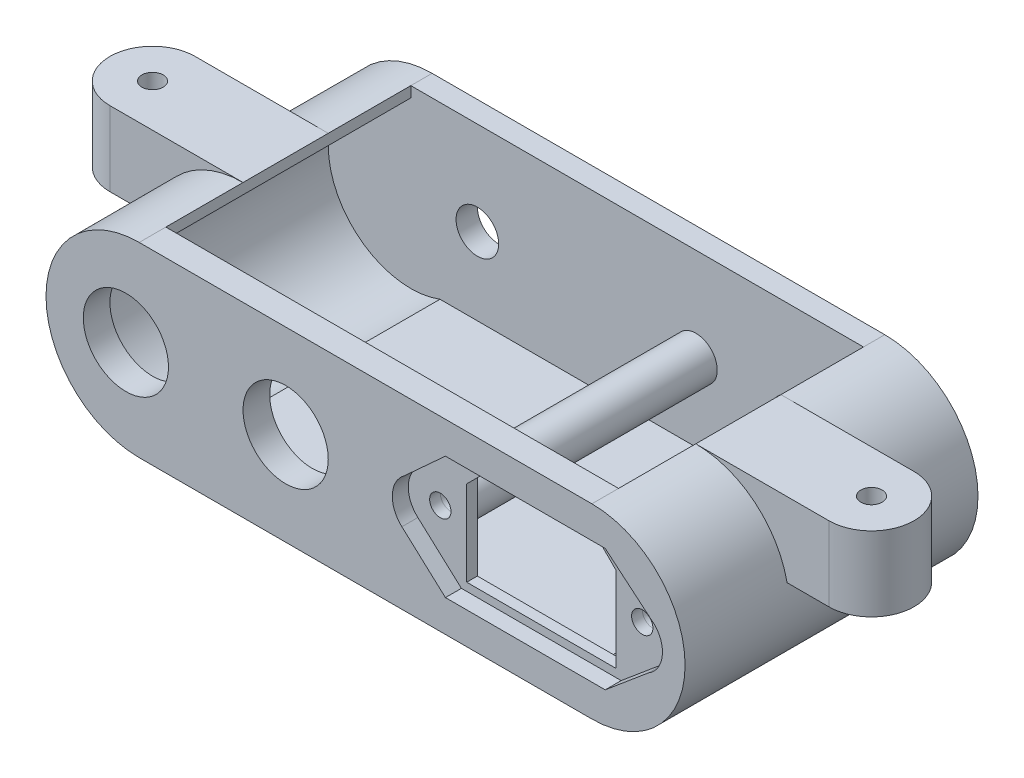
from build123d import *

# Parameters (mm, degrees)
SKETCH1_W           = 120
SKETCH1_H           = 35
BOSS_EXTRUDE1_DEPTH = 5
CUT_EXTRUDE1_DEPTH  = 3
SKETCH5_W           = 28
SKETCH5_H           = 20
CUT_EXTRUDE2_DEPTH  = 3
CHAMFER1_SIZE       = 4
SKETCH6_R           = 8
CUT_EXTRUDE3_DEPTH  = 5
SKETCH7_R           = 2
CUT_EXTRUDE4_DEPTH  = 5
CUT_EXTRUDE5_DEPTH  = 5
SKETCH9_W           = 85
SKETCH9_H           = 3
BOSS_EXTRUDE2_DEPTH = 50
SKETCH10_W          = 85
SKETCH10_H          = 4
BOSS_EXTRUDE3_DEPTH = 32
BOSS_EXTRUDE4_DEPTH = 50
SKETCH12_R          = 17.5
BOSS_EXTRUDE5_DEPTH = 4
SKETCH13_R          = 5
SKETCH13_R_2        = 4
CUT_EXTRUDE6_DEPTH  = 4
BOSS_EXTRUDE6_DEPTH = 14
SKETCH15_R          = 15.5
CUT_EXTRUDE7_DEPTH  = 46
SKETCH16_R          = 3.5
CUT_EXTRUDE8_DEPTH  = 2
SKETCH17_R          = 2
CUT_EXTRUDE9_DEPTH  = 15
BOSS_EXTRUDE7_REACH = 52
SKETCH18_R          = 4
SKETCH19_R          = 2
CUT_EXTRUDE10_DEPTH = 20
CUT_EXTRUDE10_TAPER = 3


with BuildPart() as part:
    # Sketch1 → Boss-Extrude1 (new body)
    with BuildSketch(Plane.XY):
        Rectangle(SKETCH1_W, SKETCH1_H)
    extrude(amount=BOSS_EXTRUDE1_DEPTH)

    # Sketch4 → Cut-Extrude1 (cut)
    with BuildSketch(Plane.XY.offset(5)):
        with BuildLine():
            Line((15, -11.5), (45, -11.5))
            Line((45, -11.5), (53.093205875, -4.710922816))
            ThreePointArc((53.093205875, -4.710922816), (55.688146307, -0.852928933), (54.400122175, 3.614601312))
            Line((54.400122175, 3.614601312), (45, 11.5))
            Line((45, 11.5), (15, 11.5))
            Line((15, 11.5), (7.291284487, 4.451783997))
            ThreePointArc((7.291284487, 4.451783997), (5.029380926, 0.301948581), (6.822687206, -4.07085307))
            Line((6.822687206, -4.07085307), (15, -11.5))
        make_face()
    extrude(amount=-CUT_EXTRUDE1_DEPTH, mode=Mode.SUBTRACT)

    # Sketch5 → Cut-Extrude2 (cut)
    with BuildSketch(Plane.XY.offset(2)):
        with Locations((30, 0)):
            Rectangle(SKETCH5_W, SKETCH5_H)
    extrude(amount=-CUT_EXTRUDE2_DEPTH, mode=Mode.SUBTRACT)

    # Chamfer1
    chamfer1_edges = [part.edges().sort_by_distance(p)[0] for p in [
        (44, 10, 1),
        (16, 10, 1),
    ]]
    chamfer(chamfer1_edges, length=CHAMFER1_SIZE)

    # Sketch6 → Cut-Extrude3 (cut)
    with BuildSketch(Plane.XY.offset(5)):
        with Locations((-15, 0)):
            Circle(SKETCH6_R)
        with Locations((-45, 0)):
            Circle(SKETCH6_R)
    extrude(amount=-CUT_EXTRUDE3_DEPTH, mode=Mode.SUBTRACT)

    # Sketch7 → Cut-Extrude4 (cut)
    with BuildSketch(Plane.XY.offset(2)):
        with Locations((11.038079628, 0)):
            Circle(SKETCH7_R)
        with Locations((48.961920372, 0)):
            Circle(SKETCH7_R)
    extrude(amount=-CUT_EXTRUDE4_DEPTH, mode=Mode.SUBTRACT)

    # Sketch8 → Cut-Extrude5 (cut)
    with BuildSketch(Plane.XY.offset(5)):
        with BuildLine():
            Line((-60, 17.5), (-60, -6.7e-08))
            ThreePointArc((-60, -6.7e-08), (-54.874368695, 12.374368647), (-42.5, 17.5))
            Line((-42.5, 17.5), (-60, 17.5))
        make_face()
        with BuildLine():
            Line((-60, -17.5), (-42.5, -17.5))
            ThreePointArc((-42.5, -17.5), (-54.874368647, -12.374368695), (-60, -6.7e-08))
            Line((-60, -6.7e-08), (-60, -17.5))
        make_face()
        with BuildLine():
            ThreePointArc((42.5, 17.5), (54.874368671, 12.374368671), (60, 0))
            Line((60, 0), (60, 17.5))
            Line((60, 17.5), (42.5, 17.5))
        make_face()
        with BuildLine():
            Line((42.5, -17.5), (60, -17.5))
            Line((60, -17.5), (60, 0))
            ThreePointArc((60, 0), (54.874368671, -12.374368671), (42.5, -17.5))
        make_face()
    extrude(amount=-CUT_EXTRUDE5_DEPTH, mode=Mode.SUBTRACT)

    # Sketch9 → Boss-Extrude2 (add)
    with BuildSketch(Plane(origin=(0, 0, 0), x_dir=(-1, 0, 0), z_dir=(0, 0, -1))):
        with Locations((0, -16)):
            Rectangle(SKETCH9_W, SKETCH9_H)
    extrude(amount=BOSS_EXTRUDE2_DEPTH)

    # Sketch10 → Boss-Extrude3 (add)
    with BuildSketch(Plane(origin=(0, -14.5, 0), x_dir=(1, 0, 0), z_dir=(0, 1, 0))):
        with Locations((0, 48)):
            Rectangle(SKETCH10_W, SKETCH10_H)
    extrude(amount=BOSS_EXTRUDE3_DEPTH)

    # Sketch11 → Boss-Extrude4 (add)
    with BuildSketch(Plane(origin=(0, 0, 0), x_dir=(-1, 0, 0), z_dir=(0, 0, -1))):
        with BuildLine():
            Line((42.5, 17.5), (42.5, 15.5))
            ThreePointArc((42.5, 15.5), (58, 0), (42.5, -15.5))
            Line((42.5, -15.5), (42.5, -17.5))
            ThreePointArc((42.5, -17.5), (60, 0), (42.5, 17.5))
        make_face()
        with BuildLine():
            Line((-42.5, 17.5), (-42.5, 15.5))
            ThreePointArc((-42.5, 15.5), (-58, 0), (-42.5, -15.5))
            Line((-42.5, -15.5), (-42.5, -17.5))
            ThreePointArc((-42.5, -17.5), (-60, 0), (-42.5, 17.5))
        make_face()
    extrude(amount=BOSS_EXTRUDE4_DEPTH)

    # Sketch12 → Boss-Extrude5 (add)
    with BuildSketch(Plane(origin=(0, 0, -50), x_dir=(-1, 0, 0), z_dir=(0, 0, -1))):
        with Locations((-42.5, 0)):
            Circle(SKETCH12_R)
        with Locations((42.5, 0)):
            Circle(SKETCH12_R)
    extrude(amount=-BOSS_EXTRUDE5_DEPTH)

    # Sketch13 → Cut-Extrude6 (cut)
    with BuildSketch(Plane(origin=(0, 0, -50), x_dir=(-1, 0, 0), z_dir=(0, 0, -1))):
        with Locations((-30, -2)):
            Circle(SKETCH13_R)
        with Locations((30, 0)):
            Circle(SKETCH13_R_2)
    extrude(amount=-CUT_EXTRUDE6_DEPTH, mode=Mode.SUBTRACT)

    # Sketch14 → Boss-Extrude6 (add)
    with BuildSketch(Plane(origin=(0, 17.5, 0), x_dir=(1, 0, 0), z_dir=(0, 1, 0))):
        with BuildLine():
            Line((-42.5, 14.5), (-67.5, 14.5))
            ThreePointArc((-67.5, 14.5), (-75.5, 22.5), (-67.5, 30.5))
            Line((-67.5, 30.5), (-42.5, 30.5))
            Line((-42.5, 30.5), (-42.5, 14.5))
        make_face()
        with BuildLine():
            Line((42.5, 30.5), (67.5, 30.5))
            ThreePointArc((67.5, 30.5), (75.5, 22.5), (67.5, 14.5))
            Line((67.5, 14.5), (42.5, 14.5))
            Line((42.5, 14.5), (42.5, 30.5))
        make_face()
    extrude(amount=-BOSS_EXTRUDE6_DEPTH)

    # Sketch15 → Cut-Extrude7 (cut)
    with BuildSketch(Plane(origin=(0, 0, 0), x_dir=(-1, 0, 0), z_dir=(0, 0, -1))):
        with Locations((-42.5, 0)):
            Circle(SKETCH15_R)
        with Locations((42.5, 0)):
            Circle(SKETCH15_R)
    extrude(amount=CUT_EXTRUDE7_DEPTH, mode=Mode.SUBTRACT)

    # Sketch16 → Cut-Extrude8 (cut)
    with BuildSketch(Plane.XZ.offset(-3.5)):
        with Locations((67.5, -22.5)):
            Circle(SKETCH16_R)
        with Locations((-67.5, -22.5)):
            Circle(SKETCH16_R)
    extrude(amount=-CUT_EXTRUDE8_DEPTH, mode=Mode.SUBTRACT)

    # Sketch17 → Cut-Extrude9 (cut, through all)
    with BuildSketch(Plane.XZ.offset(-3.5)):
        with Locations((-67.5, -22.5)):
            Circle(SKETCH17_R)
        with Locations((67.5, -22.5)):
            Circle(SKETCH17_R)
    extrude(amount=-CUT_EXTRUDE9_DEPTH, mode=Mode.SUBTRACT)

    # Sketch18 → Boss-Extrude7 (add, up to next)
    with BuildSketch(Plane(origin=(0, 0, 0), x_dir=(-1, 0, 0), z_dir=(0, 0, -1)), mode=Mode.PRIVATE) as boss_extrude7_sk1:
        with Locations((-48.961920372, 0)):
            Circle(SKETCH18_R)
    boss_extrude7_tool1 = extrude(boss_extrude7_sk1.sketch, amount=BOSS_EXTRUDE7_REACH, mode=Mode.PRIVATE) - part.part
    add(boss_extrude7_tool1.solids().sort_by_distance((48.96192, 0, 0))[0])
    # Sketch18 → Boss-Extrude7 (add, up to next)
    with BuildSketch(Plane(origin=(0, 0, 0), x_dir=(-1, 0, 0), z_dir=(0, 0, -1)), mode=Mode.PRIVATE) as boss_extrude7_sk2:
        with Locations((-11.038079628, 0)):
            Circle(SKETCH18_R)
    boss_extrude7_tool2 = extrude(boss_extrude7_sk2.sketch, amount=BOSS_EXTRUDE7_REACH, mode=Mode.PRIVATE) - part.part
    add(boss_extrude7_tool2.solids().sort_by_distance((11.03808, 0, 0))[0])

    # Sketch19 → Cut-Extrude10 (cut)
    with BuildSketch(Plane.XY):
        with Locations((11.038079628, 0)):
            Circle(SKETCH19_R)
        with Locations((48.961920372, 0)):
            Circle(SKETCH19_R)
    extrude(amount=-CUT_EXTRUDE10_DEPTH, taper=CUT_EXTRUDE10_TAPER, mode=Mode.SUBTRACT)


solid = part.part
